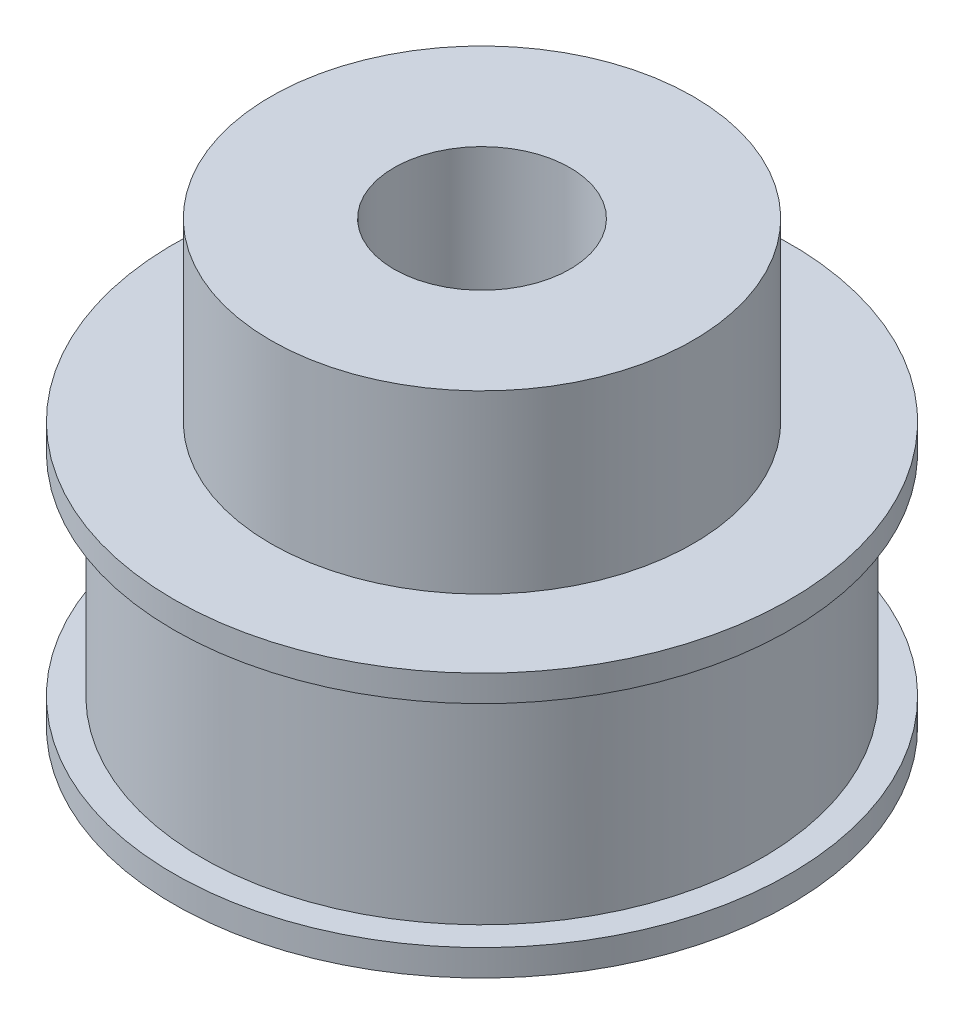
from build123d import *

# Parameters (mm, degrees)
SKETCH1_R           = 32.34
BOSS_EXTRUDE1_DEPTH = 15
SKETCH2_R           = 12
BOSS_EXTRUDE2_DEPTH = 10
SKETCH3_R           = 5
CUT_EXTRUDE1_DEPTH  = 26
SKETCH4_R           = 32.34
SKETCH4_R_2         = 15.915
CUT_EXTRUDE3_DEPTH  = 15
SKETCH5_R           = 17.5
SKETCH5_R_2         = 15.915
BOSS_EXTRUDE3_DEPTH = 1.5
SKETCH6_R           = 17.5
SKETCH6_R_2         = 15.915
BOSS_EXTRUDE4_DEPTH = 1.5


with BuildPart() as part:
    # Sketch1 → Boss-Extrude1 (new body)
    with BuildSketch(Plane(origin=(0, 0, 0), x_dir=(1, 0, 0), z_dir=(0, 1, 0))):
        Circle(SKETCH1_R)
    extrude(amount=BOSS_EXTRUDE1_DEPTH)

    # Sketch2 → Boss-Extrude2 (add)
    with BuildSketch(Plane(origin=(0, 15, 0), x_dir=(1, 0, 0), z_dir=(0, 1, 0))):
        Circle(SKETCH2_R)
    extrude(amount=BOSS_EXTRUDE2_DEPTH)

    # Sketch3 → Cut-Extrude1 (cut)
    with BuildSketch(Plane(origin=(0, 25, 0), x_dir=(1, 0, 0), z_dir=(0, 1, 0))):
        Circle(SKETCH3_R)
    extrude(amount=-CUT_EXTRUDE1_DEPTH, mode=Mode.SUBTRACT)

    # Sketch4 → Cut-Extrude3 (cut)
    with BuildSketch(Plane.XZ):
        Circle(SKETCH4_R)
        Circle(SKETCH4_R_2, mode=Mode.SUBTRACT)
    extrude(amount=-CUT_EXTRUDE3_DEPTH, mode=Mode.SUBTRACT)

    # Sketch5 → Boss-Extrude3 (add)
    with BuildSketch(Plane.XZ):
        Circle(SKETCH5_R)
        Circle(SKETCH5_R_2, mode=Mode.SUBTRACT)
    extrude(amount=-BOSS_EXTRUDE3_DEPTH)

    # Sketch6 → Boss-Extrude4 (add)
    with BuildSketch(Plane(origin=(0, 15, 0), x_dir=(1, 0, 0), z_dir=(0, 1, 0))):
        Circle(SKETCH6_R)
        Circle(SKETCH6_R_2, mode=Mode.SUBTRACT)
    extrude(amount=-BOSS_EXTRUDE4_DEPTH)


solid = part.part
